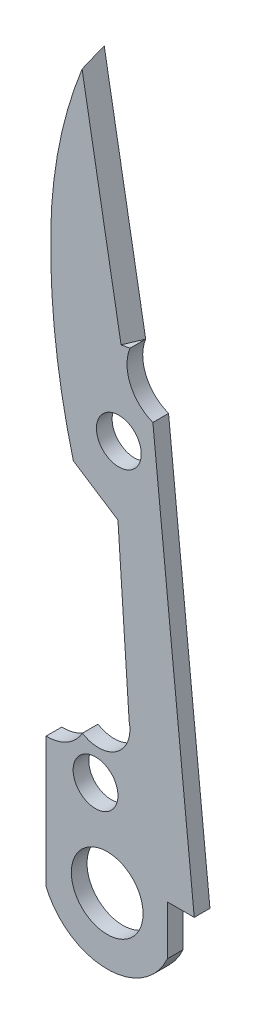
from build123d import *

# Parameters (mm, degrees)
SKETCH1_R           = 1.27
BOSS_EXTRUDE3_DEPTH = 0.889
SKETCH3_R           = 2.032
CUT_EXTRUDE1_DEPTH  = 1.889
CUT_EXTRUDE2_DEPTH  = 24.373709


with BuildPart() as part:
    # Sketch1 → Boss-Extrude3 (new body)
    with BuildSketch(Plane.XY):
        with BuildLine():
            Line((53.882826418, 59.421700713), (56.230021181, 46.213700713))
            ThreePointArc((56.230021181, 46.213700713), (56.248351323, 44.442871919), (57.525920997, 43.216500713))
            Line((57.525920997, 43.216500713), (59.870620113, 20.102500713))
            Line((59.870620113, 20.102500713), (58.346620113, 20.102500713))
            Line((58.346620113, 20.102500713), (58.346620113, 17.308500713))
            ThreePointArc((58.346620113, 17.308500713), (54.868586202, 15.099346005), (51.475082329, 17.436270454))
            Line((51.475082329, 17.436270454), (51.475082329, 24.802270454))
            ThreePointArc((51.475082329, 24.802270454), (52.66510076, 25.100716041), (53.529437672, 25.971425715))
            ThreePointArc((53.529437672, 25.971425715), (55.487269989, 26.051421604), (56.18260068, 27.883366459))
            Line((56.18260068, 27.883366459), (55.54760068, 37.433766459))
            Line((55.54760068, 37.433766459), (53.019584786, 39.084766459))
            ThreePointArc((53.019584786, 39.084766459), (52.015147123, 44.373161392), (51.741430513, 49.749135277))
            ThreePointArc((51.741430513, 49.749135277), (52.3260698, 54.693025851), (53.882826418, 59.421700713))
        make_face()
        with Locations((55.59840068, 41.336900713)):
            Circle(SKETCH1_R, mode=Mode.SUBTRACT)
        with Locations((54.27760068, 23.912500713)):
            Circle(SKETCH1_R, mode=Mode.SUBTRACT)
    extrude(amount=BOSS_EXTRUDE3_DEPTH)

    # Sketch3 → Cut-Extrude1 (cut, through all)
    with BuildSketch(Plane.XY.offset(0.889)):
        with Locations((54.93800068, 18.832500713)):
            Circle(SKETCH3_R)
    extrude(amount=-CUT_EXTRUDE1_DEPTH, mode=Mode.SUBTRACT)

    # Sketch4 → Cut-Extrude2 (cut)
    with BuildSketch(Plane(origin=(-10.504426242, 59.109905984, 0), x_dir=(0.984573992, 0.174968725, 0), z_dir=(-0.174968725, 0.984573992, 0))):
        Polygon((63.448568698, 0), (63.448568698, -0.889), (62.935304309, -0.889), align=None)
    extrude(amount=-CUT_EXTRUDE2_DEPTH, mode=Mode.SUBTRACT)


solid = part.part
